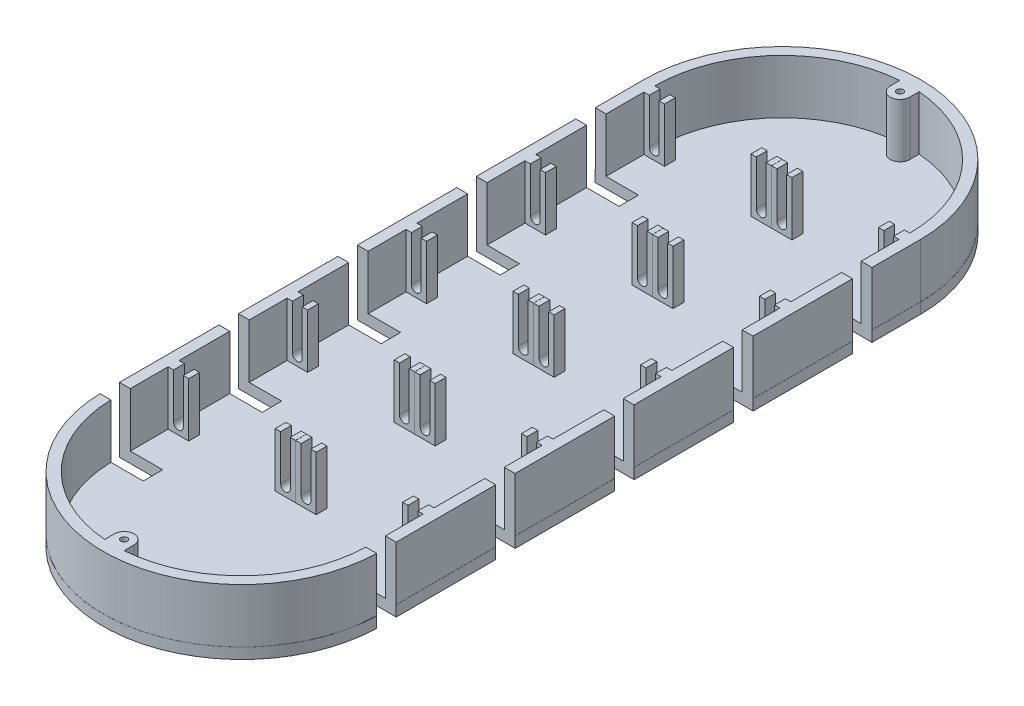
from build123d import *

# Parameters (mm, degrees)
BOSS_EXTRUDE1_DEPTH  = 5
BOSS_EXTRUDE2_DEPTH  = 25
SKETCH3_W            = 9.5
SKETCH3_H            = 5
SKETCH3_W_2          = 9.448385448
BOSS_EXTRUDE4_DEPTH  = 25
CUT_EXTRUDE3_DEPTH   = 228
SKETCH7_W            = 5
SKETCH7_H            = 9
SKETCH7_W_2          = 5.025807276
SKETCH7_W_3          = 6.322468702
CUT_EXTRUDE7_DEPTH   = 32
SKETCH8_W            = 7.777866372
SKETCH8_H            = 9
SKETCH8_W_2          = 20
SKETCH8_W_3          = 11.098706951
SKETCH8_W_4          = 13.710972022
CUT_EXTRUDE9_DEPTH   = 17
SKETCH9_W            = 4.5
SKETCH9_H            = 1.391177739
SKETCH9_H_2          = 0.965826369
BOSS_EXTRUDE10_DEPTH = 25


with BuildPart() as part:
    # Sketch1 → Boss-Extrude1 (new body)
    with BuildSketch(Plane(origin=(0, 0, 0), x_dir=(1, 0, 0), z_dir=(0, 1, 0))):
        with BuildLine():
            Line((-64, 250), (-64, 0))
            ThreePointArc((-64, 0), (0, -64), (64, 0))
            Line((64, 0), (64, 250))
            ThreePointArc((64, 250), (0, 314), (-64, 250))
        make_face()
    extrude(amount=BOSS_EXTRUDE1_DEPTH)

    # Sketch2 → Boss-Extrude2 (add)
    with BuildSketch(Plane(origin=(0, 5, 0), x_dir=(1, 0, 0), z_dir=(0, 1, 0))):
        with BuildLine():
            Line((-63.974192724, 0), (-63.974192724, 250))
            ThreePointArc((-63.974192724, 250), (0, 313.974192724), (63.974192724, 250))
            Line((63.974192724, 250), (63.974192724, 0))
            ThreePointArc((63.974192724, 0), (0, -63.974192724), (-63.974192724, 0))
        make_face()
        with BuildLine():
            Line((-58.974192724, 0), (-58.974192724, 250))
            ThreePointArc((-58.974192724, 250), (0, 308.974192724), (58.974192724, 250))
            Line((58.974192724, 250), (58.974192724, 0))
            ThreePointArc((58.974192724, 0), (0, -58.974192724), (-58.974192724, 0))
        make_face(mode=Mode.SUBTRACT)
    extrude(amount=BOSS_EXTRUDE2_DEPTH)

    # Sketch3 → Boss-Extrude4 (add)
    with BuildSketch(Plane(origin=(0, 5, 0), x_dir=(1, 0, 0), z_dir=(0, 1, 0))):
        with Locations((-54.224192724, 27.5)):
            Rectangle(SKETCH3_W, SKETCH3_H)
        with Locations((-4.75, 27.5)):
            Rectangle(SKETCH3_W_2, SKETCH3_H)
        with Locations((4.75, 27.5)):
            Rectangle(SKETCH3_W_2, SKETCH3_H)
        with Locations((54.224192724, 27.5)):
            Rectangle(SKETCH3_W, SKETCH3_H)
        with Locations((54.224192724, 82.5)):
            Rectangle(SKETCH3_W, SKETCH3_H)
        with Locations((4.75, 82.5)):
            Rectangle(SKETCH3_W_2, SKETCH3_H)
        with Locations((-4.75, 82.5)):
            Rectangle(SKETCH3_W_2, SKETCH3_H)
        with Locations((-54.224192724, 82.5)):
            Rectangle(SKETCH3_W, SKETCH3_H)
        with Locations((-54.224192724, 137.5)):
            Rectangle(SKETCH3_W, SKETCH3_H)
        with Locations((-4.75, 137.5)):
            Rectangle(SKETCH3_W_2, SKETCH3_H)
        with Locations((4.75, 137.5)):
            Rectangle(SKETCH3_W_2, SKETCH3_H)
        with Locations((54.224192724, 137.5)):
            Rectangle(SKETCH3_W, SKETCH3_H)
        with Locations((54.224192724, 192.5)):
            Rectangle(SKETCH3_W, SKETCH3_H)
        with Locations((4.75, 192.5)):
            Rectangle(SKETCH3_W_2, SKETCH3_H)
        with Locations((-4.75, 192.5)):
            Rectangle(SKETCH3_W_2, SKETCH3_H)
        with Locations((-54.224192724, 192.5)):
            Rectangle(SKETCH3_W, SKETCH3_H)
        with Locations((-54.224192724, 247.5)):
            Rectangle(SKETCH3_W, SKETCH3_H)
        with Locations((-4.75, 247.5)):
            Rectangle(SKETCH3_W_2, SKETCH3_H)
        with Locations((4.75, 247.5)):
            Rectangle(SKETCH3_W_2, SKETCH3_H)
        with Locations((54.224192724, 247.5)):
            Rectangle(SKETCH3_W, SKETCH3_H)
    extrude(amount=BOSS_EXTRUDE4_DEPTH)

    # Sketch6 → Cut-Extrude3 (cut)
    with BuildSketch(Plane.XY.offset(-25)):
        with BuildLine():
            Line((-56.474192724, 30), (-56.474192724, 9.25))
            ThreePointArc((-56.474192724, 9.25), (-54.224192724, 7), (-51.974192724, 9.25))
            Line((-51.974192724, 9.25), (-51.974192724, 30))
            Line((-51.974192724, 30), (-56.474192724, 30))
        make_face()
        with BuildLine():
            Line((-7, 30), (-7, 9.25))
            ThreePointArc((-7, 9.25), (-4.75, 7), (-2.5, 9.25))
            Line((-2.5, 9.25), (-2.5, 30))
            Line((-2.5, 30), (-7, 30))
        make_face()
        with BuildLine():
            Line((2.5, 30), (2.5, 9.25))
            ThreePointArc((2.5, 9.25), (4.75, 7), (7, 9.25))
            Line((7, 9.25), (7, 30))
            Line((7, 30), (2.5, 30))
        make_face()
        with BuildLine():
            Line((51.974192724, 30), (51.974192724, 9.25))
            ThreePointArc((51.974192724, 9.25), (54.224192724, 7), (56.474192724, 9.25))
            Line((56.474192724, 9.25), (56.474192724, 30))
            Line((56.474192724, 30), (51.974192724, 30))
        make_face()
    extrude(amount=-CUT_EXTRUDE3_DEPTH, mode=Mode.SUBTRACT)

    # Sketch7 → Cut-Extrude7 (cut)
    with BuildSketch(Plane(origin=(0, 5, 0), x_dir=(1, 0, 0), z_dir=(0, 1, 0))):
        with Locations((-61.474192724, 58)):
            Rectangle(SKETCH7_W, SKETCH7_H)
        with Locations((-61.474192724, 168)):
            Rectangle(SKETCH7_W, SKETCH7_H)
        with Locations((61.487096362, 223)):
            Rectangle(SKETCH7_W_2, SKETCH7_H)
        with Locations((61.474192724, 168)):
            Rectangle(SKETCH7_W, SKETCH7_H)
        with Locations((61.474192724, 113)):
            Rectangle(SKETCH7_W, SKETCH7_H)
        with Locations((61.474192724, 58)):
            Rectangle(SKETCH7_W, SKETCH7_H)
        with Locations((60.838765649, 3)):
            Rectangle(SKETCH7_W_3, SKETCH7_H)
        with Locations((-60.838765649, 3)):
            Rectangle(SKETCH7_W_3, SKETCH7_H)
        with Locations((-61.474192724, 113)):
            Rectangle(SKETCH7_W, SKETCH7_H)
        with Locations((-61.487096362, 223)):
            Rectangle(SKETCH7_W_2, SKETCH7_H)
    extrude(amount=CUT_EXTRUDE7_DEPTH, mode=Mode.SUBTRACT)

    # Sketch8 → Cut-Extrude9 (cut)
    with BuildSketch(Plane(origin=(0, 5, 0), x_dir=(1, 0, 0), z_dir=(0, 1, 0))):
        with Locations((-67.86312591, 223)):
            Rectangle(SKETCH8_W, SKETCH8_H)
        with Locations((-53.974192724, 223)):
            Rectangle(SKETCH8_W_2, SKETCH8_H)
        with Locations((-69.5235462, 168)):
            Rectangle(SKETCH8_W_3, SKETCH8_H)
        with Locations((-53.974192724, 168)):
            Rectangle(SKETCH8_W_2, SKETCH8_H)
        with Locations((-70.829678735, 113)):
            Rectangle(SKETCH8_W_4, SKETCH8_H)
        with Locations((-53.974192724, 113)):
            Rectangle(SKETCH8_W_2, SKETCH8_H)
        with Locations((-69.5235462, 58)):
            Rectangle(SKETCH8_W_3, SKETCH8_H)
        with Locations((-53.974192724, 58)):
            Rectangle(SKETCH8_W_2, SKETCH8_H)
        with Locations((-69.5235462, 3)):
            Rectangle(SKETCH8_W_3, SKETCH8_H)
        with Locations((-53.974192724, 3)):
            Rectangle(SKETCH8_W_2, SKETCH8_H)
        with Locations((53.974192724, 3)):
            Rectangle(SKETCH8_W_2, SKETCH8_H)
        with Locations((69.5235462, 3)):
            Rectangle(SKETCH8_W_3, SKETCH8_H)
        with Locations((69.5235462, 58)):
            Rectangle(SKETCH8_W_3, SKETCH8_H)
        with Locations((53.974192724, 58)):
            Rectangle(SKETCH8_W_2, SKETCH8_H)
        with Locations((70.829678735, 113)):
            Rectangle(SKETCH8_W_4, SKETCH8_H)
        with Locations((53.974192724, 113)):
            Rectangle(SKETCH8_W_2, SKETCH8_H)
        with Locations((69.5235462, 168)):
            Rectangle(SKETCH8_W_3, SKETCH8_H)
        with Locations((53.974192724, 168)):
            Rectangle(SKETCH8_W_2, SKETCH8_H)
        with Locations((67.86312591, 223)):
            Rectangle(SKETCH8_W, SKETCH8_H)
        with Locations((53.974192724, 223)):
            Rectangle(SKETCH8_W_2, SKETCH8_H)
    extrude(amount=-CUT_EXTRUDE9_DEPTH, mode=Mode.SUBTRACT)

    # Sketch9 → Boss-Extrude10 (add)
    with BuildSketch(Plane(origin=(0, 5, 0), x_dir=(1, 0, 0), z_dir=(0, 1, 0))):
        with BuildLine():
            Line((0, 305.956787905), (0, 308.956787905))
            ThreePointArc((0, 308.956787905), (-3.093145102, 307.725190172), (-4.493174428, 304.704544961))
            Line((-4.493174428, 304.704544961), (-4.492355892, 304.194607548))
            ThreePointArc((-4.492355892, 304.194607548), (-3.087894784, 301.183424833), (0, 299.956787905))
            Line((0, 299.956787905), (0, 302.956787905))
            ThreePointArc((0, 302.956787905), (-1.5, 304.456787905), (0, 305.956787905))
        make_face()
        with BuildLine():
            ThreePointArc((4.5, 304.456787905), (3.181980515, 307.63876842), (0, 308.956787905))
            Line((0, 308.956787905), (0, 305.956787905))
            ThreePointArc((0, 305.956787905), (1.060660172, 305.517448077), (1.5, 304.456787905))
            ThreePointArc((1.5, 304.456787905), (1.060660172, 303.396127733), (0, 302.956787905))
            Line((0, 302.956787905), (0, 299.956787905))
            ThreePointArc((0, 299.956787905), (3.181980515, 301.27480739), (4.5, 304.456787905))
        make_face()
        with BuildLine():
            Line((4.5, 308.956787905), (0, 308.956787905))
            ThreePointArc((0, 308.956787905), (3.181980515, 307.63876842), (4.5, 304.456787905))
            Line((4.5, 304.456787905), (4.5, 308.956787905))
        make_face()
        with BuildLine():
            ThreePointArc((-4.493174428, 304.704544961), (-3.093145102, 307.725190172), (0, 308.956787905))
            Line((0, 308.956787905), (-4.5, 308.956787905))
            Line((-4.5, 308.956787905), (-4.493174428, 304.704544961))
        make_face()
        with Locations((-2.25, 309.652376774)):
            Rectangle(SKETCH9_W, SKETCH9_H)
        with Locations((2.25, 309.652376774)):
            Rectangle(SKETCH9_W, SKETCH9_H)
        with Locations((-2.25, -59.285170007)):
            Rectangle(SKETCH9_W, SKETCH9_H_2)
        with BuildLine():
            ThreePointArc((0, -58.802256822), (-3.181980515, -57.484237338), (-4.5, -54.302256822))
            Line((-4.5, -54.302256822), (-4.5, -58.802256822))
            Line((-4.5, -58.802256822), (0, -58.802256822))
        make_face()
        with BuildLine():
            ThreePointArc((4.5, -54.302256822), (3.181980515, -51.120276307), (0, -49.802256822))
            Line((0, -49.802256822), (0, -52.802256822))
            ThreePointArc((0, -52.802256822), (1.060660172, -53.241596651), (1.5, -54.302256822))
            ThreePointArc((1.5, -54.302256822), (1.060660172, -55.362916994), (0, -55.802256822))
            Line((0, -55.802256822), (0, -58.802256822))
            ThreePointArc((0, -58.802256822), (3.181980515, -57.484237338), (4.5, -54.302256822))
        make_face()
        with BuildLine():
            Line((0, -52.802256822), (0, -49.802256822))
            ThreePointArc((0, -49.802256822), (-3.181980515, -51.120276307), (-4.5, -54.302256822))
            ThreePointArc((-4.5, -54.302256822), (-3.181980515, -57.484237338), (0, -58.802256822))
            Line((0, -58.802256822), (0, -55.802256822))
            ThreePointArc((0, -55.802256822), (-1.5, -54.302256822), (0, -52.802256822))
        make_face()
        with BuildLine():
            Line((4.5, -57.865808047), (4.5, -54.302256822))
            ThreePointArc((4.5, -54.302256822), (3.181980515, -57.484237338), (0, -58.802256822))
            Line((0, -58.802256822), (4.5, -58.802256822))
            Line((4.5, -58.802256822), (4.5, -57.865808047))
        make_face()
        with Locations((2.25, -59.285170007)):
            Rectangle(SKETCH9_W, SKETCH9_H_2)
    extrude(amount=BOSS_EXTRUDE10_DEPTH)


solid = part.part
